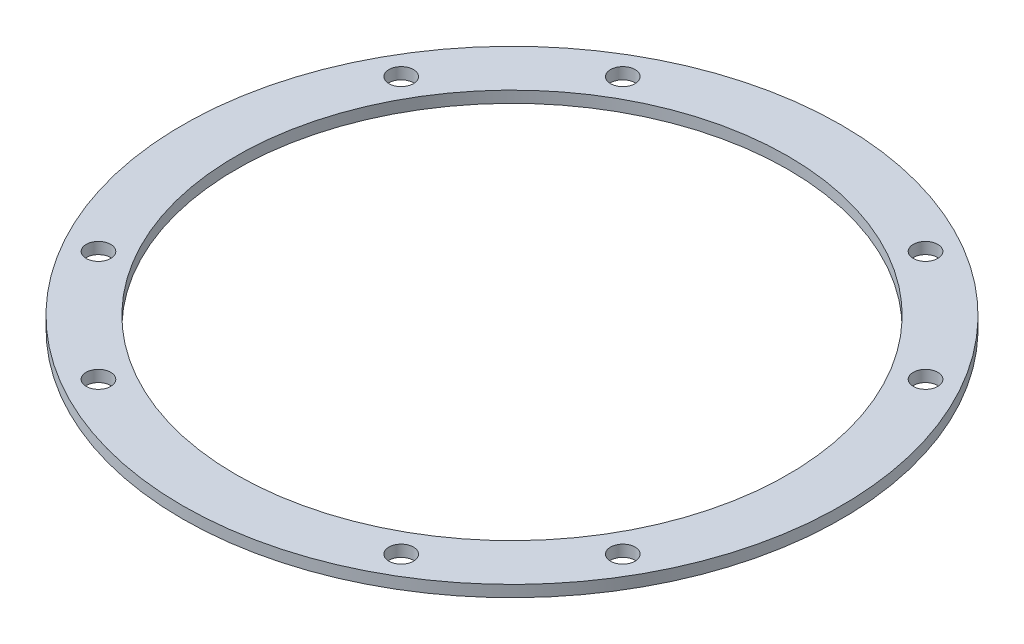
from build123d import *

# Parameters (mm, degrees)
SKETCH1_R                  = 43
SKETCH1_R_2                = 36
BOSS_EXTRUDE1_DEPTH        = 0.75
F_3_2_3_2_DIAMETER_HOLE1_D = 3.2


with BuildPart() as part:
    # Sketch1 → Boss-Extrude1 (new body, symmetric)
    with BuildSketch(Plane(origin=(0, 0, 0), x_dir=(1, 0, 0), z_dir=(0, 1, 0))):
        Circle(SKETCH1_R)
        Circle(SKETCH1_R_2, mode=Mode.SUBTRACT)
    extrude(amount=BOSS_EXTRUDE1_DEPTH, both=True)

    # Ø3.2 (3.2) Diameter Hole1 (through all)
    with Locations(Plane(origin=(0, 0.75, 0), x_dir=(1, 0, 0), z_dir=(0, 1, 0))):
        with Locations((-34.208003449, -19.75), (-34.208003449, 19.75), (-19.75, 34.208003449), (19.75, 34.208003449), (34.208003449, 19.75), (34.208003449, -19.75), (19.75, -34.208003449), (-19.75, -34.208003449), (0, 0)):
            Hole(F_3_2_3_2_DIAMETER_HOLE1_D / 2)


solid = part.part
